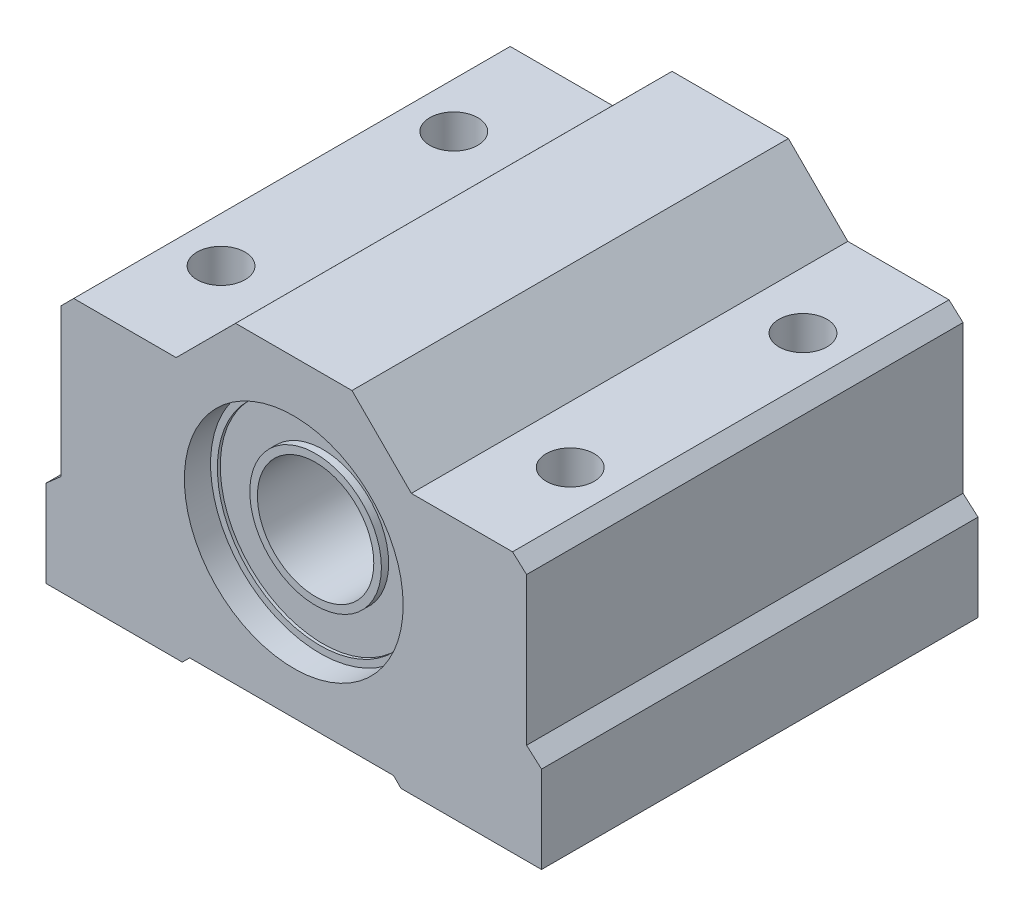
from build123d import *

# Parameters (mm, degrees)
ESQUISSE1_R             = 7.519017315
BOSS_EXTRU_1_DEPTH      = 30
ESQUISSE1_3_R           = 7.051788316
ESQUISSE1_3_R_2         = 4.523392982
BOSS_EXTRU_2_DEPTH      = 28
ESQUISSE1_4_R           = 7.519017315
ESQUISSE1_4_R_2         = 7.051788316
BOSS_EXTRU_3_DEPTH      = 30
ESQUISSE1_5_R           = 4.523392982
ESQUISSE1_5_R_2         = 4
BOSS_EXTRU_4_DEPTH      = 28.5
ESQUISSE1_6_R           = 4.523392982
ESQUISSE1_6_R_2         = 4
ENL_V_MAT_EXTRU_1_DEPTH = 1.5
ESQUISSE1_7_R           = 7.051788316
ESQUISSE1_7_R_2         = 4.523392982
ENL_V_MAT_EXTRU_2_DEPTH = 2
ESQUISSE1_8_R           = 7.519017315
ESQUISSE1_8_R_2         = 7.051788316
ENL_V_MAT_EXTRU_3_DEPTH = 1.8
ENL_V_START             = -30
ESQUISSE1_9_R           = 7.519017315
ESQUISSE1_9_R_2         = 7.051788316
ENL_V_MAT_EXTRU_4_DEPTH = 1.8
M4X0_7_TAPPED_HOLE1_D   = 3.3


with BuildPart() as part:
    # Esquisse1 → Boss.-Extru.1 (new body)
    with BuildSketch(Plane.XY):
        Polygon((-15.997216081, -4.089203195), (-17.03, -5.004453984), (-17.03, -10.973805396), (-7.66267479, -10.973805396), (-7.153229177, -10.464359784), (6.857616233, -10.464359784), (7.367061846, -10.973805396), (17.03, -10.973805396), (17.03, -4.995255883), (16.002783919, -4.089203195), (16.002783919, 6.07141612), (15.037454618, 6.944265115), (8.081929489, 6.944265115), (4, 11.026194604), (-4, 11.026194604), (-8.083891517, 6.944265115), (-15.124367087, 6.944265115), (-15.997216081, 6.07141612), align=None)
        Circle(ESQUISSE1_R, mode=Mode.SUBTRACT)
    extrude(amount=-BOSS_EXTRU_1_DEPTH)



with BuildPart() as body_2:
    # Esquisse1_3 → Boss.-Extru.2 (new body)
    with BuildSketch(Plane.XY):
        Circle(ESQUISSE1_3_R)
        Circle(ESQUISSE1_3_R_2, mode=Mode.SUBTRACT)
    extrude(amount=-BOSS_EXTRU_2_DEPTH)


with BuildPart() as part_1:
    add(part.part)

    add(body_2.part)  # Boss.-Extru.3 merges body 2
    # Esquisse1_4 → Boss.-Extru.3 (add)
    with BuildSketch(Plane.XY):
        Circle(ESQUISSE1_4_R)
        Circle(ESQUISSE1_4_R_2, mode=Mode.SUBTRACT)
    extrude(amount=-BOSS_EXTRU_3_DEPTH)

    # Esquisse1_5 → Boss.-Extru.4 (add)
    with BuildSketch(Plane.XY):
        Circle(ESQUISSE1_5_R)
        Circle(ESQUISSE1_5_R_2, mode=Mode.SUBTRACT)
    extrude(amount=-BOSS_EXTRU_4_DEPTH)

    # Esquisse1_6 → Enl_v. mat.-Extru.1 (cut)
    with BuildSketch(Plane.XY):
        Circle(ESQUISSE1_6_R)
        Circle(ESQUISSE1_6_R_2, mode=Mode.SUBTRACT)
    extrude(amount=-ENL_V_MAT_EXTRU_1_DEPTH, mode=Mode.SUBTRACT)

    # Esquisse1_7 → Enl_v. mat.-Extru.2 (cut)
    with BuildSketch(Plane.XY):
        Circle(ESQUISSE1_7_R)
        Circle(ESQUISSE1_7_R_2, mode=Mode.SUBTRACT)
    extrude(amount=-ENL_V_MAT_EXTRU_2_DEPTH, mode=Mode.SUBTRACT)

    # Esquisse1_8 → Enl_v. mat.-Extru.3 (cut)
    with BuildSketch(Plane.XY):
        Circle(ESQUISSE1_8_R)
        Circle(ESQUISSE1_8_R_2, mode=Mode.SUBTRACT)
    extrude(amount=-ENL_V_MAT_EXTRU_3_DEPTH, mode=Mode.SUBTRACT)

    # Esquisse1_9 → Enl_v. mat.-Extru.4 (cut)
    with BuildSketch(Plane.XY.offset(ENL_V_START)):
        Circle(ESQUISSE1_9_R)
        Circle(ESQUISSE1_9_R_2, mode=Mode.SUBTRACT)
    extrude(amount=ENL_V_MAT_EXTRU_4_DEPTH, mode=Mode.SUBTRACT)

    # M4x0.7 Tapped Hole1 (through all)
    with Locations(Plane(origin=(0, -10.973805396, 0), x_dir=(-1, 0, 0), z_dir=(0, -1, 0))):
        with Locations((-12, 7), (-12, 23), (12, 23), (12, 7)):
            Hole(M4X0_7_TAPPED_HOLE1_D / 2)


solid = part_1.part
